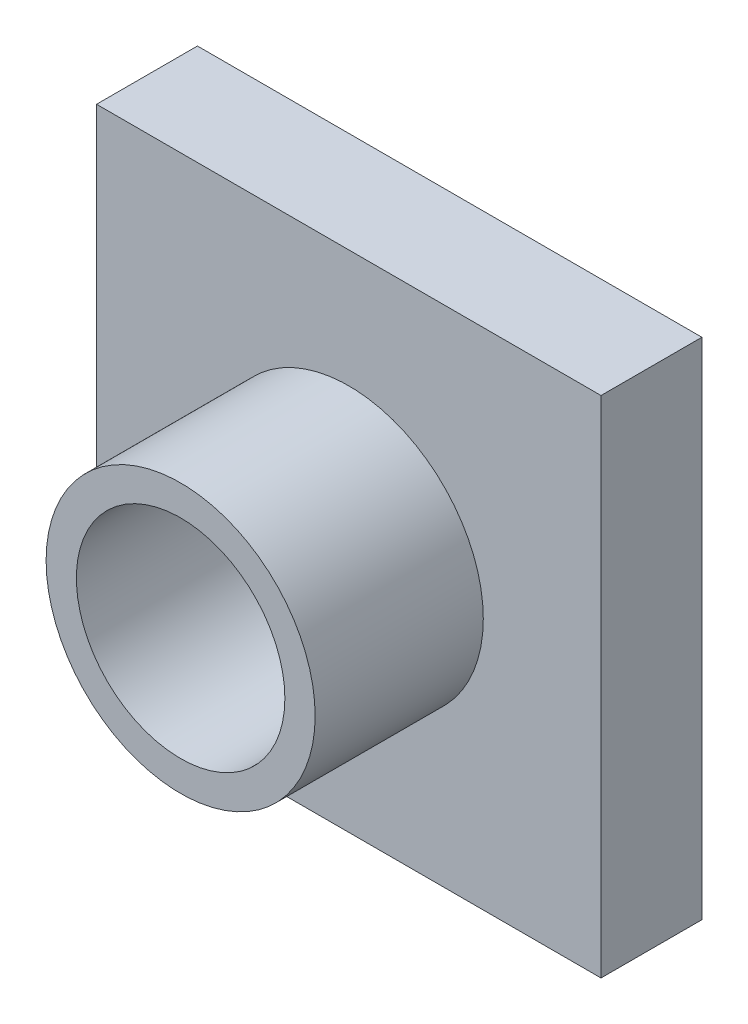
from build123d import *

# Parameters (mm, degrees)
SKETCH3_W           = 15
SKETCH3_H           = 15
BOSS_EXTRUDE1_DEPTH = 3
SKETCH4_R           = 4
BOSS_EXTRUDE2_DEPTH = 5
SKETCH5_R           = 3.1
CUT_EXTRUDE1_DEPTH  = 4.5


with BuildPart() as part:
    # Sketch3 → Boss-Extrude1 (new body)
    with BuildSketch(Plane.XY):
        Rectangle(SKETCH3_W, SKETCH3_H)
    extrude(amount=BOSS_EXTRUDE1_DEPTH)

    # Sketch4 → Boss-Extrude2 (add)
    with BuildSketch(Plane.XY.offset(3)):
        Circle(SKETCH4_R)
    extrude(amount=BOSS_EXTRUDE2_DEPTH)

    # Sketch5 → Cut-Extrude1 (cut)
    with BuildSketch(Plane.XY.offset(8)):
        Circle(SKETCH5_R)
    extrude(amount=-CUT_EXTRUDE1_DEPTH, mode=Mode.SUBTRACT)


solid = part.part
